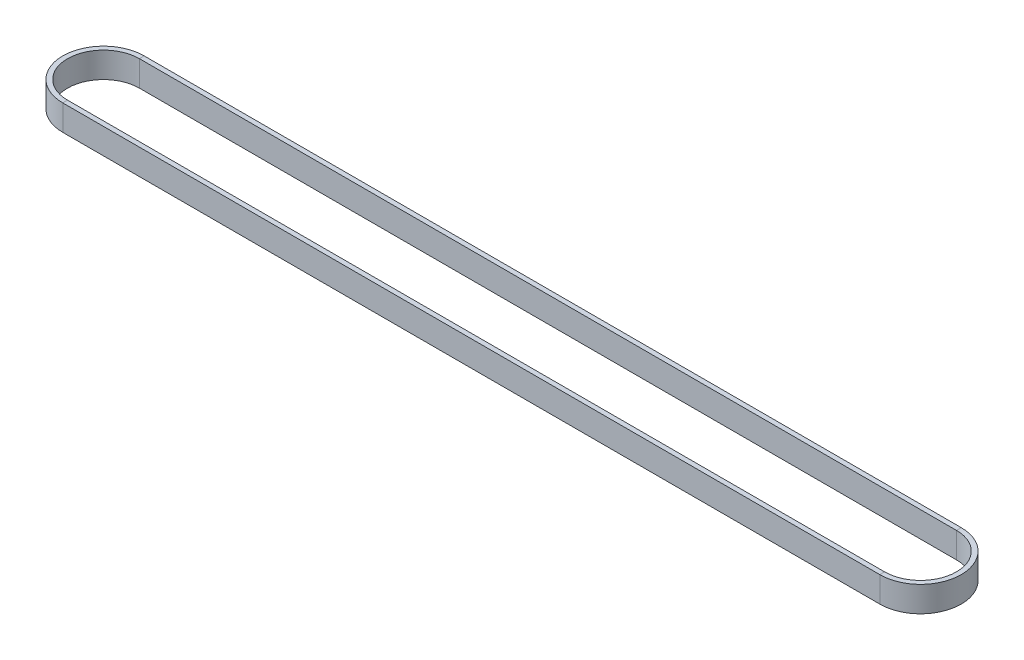
from build123d import *

# Parameters (mm, degrees)
SKETCH2_W = 1.905
SKETCH2_H = 10.16


with BuildPart() as part:
    # Sweep1: sweep along a path in Sketch1
    with BuildLine(Plane(origin=(0, 0, 0), x_dir=(1, 0, 0), z_dir=(0, 1, 0))) as sweep1_path:
        Line((0, 15.24), (325.005160504, 15.24))
        ThreePointArc((325.005160504, 15.24), (340.245160504, 0), (325.005160504, -15.24))
        Line((325.005160504, -15.24), (0, -15.24))
        ThreePointArc((0, -15.24), (-15.24, 0), (0, 15.24))
    # Sketch2 → Sweep1 (sweep)
    with BuildSketch(Plane(origin=(0, 0, 0), x_dir=(0, 0, -1), z_dir=(1, 0, 0))):
        with Locations((-15.24, 0)):
            Rectangle(SKETCH2_W, SKETCH2_H)
    sweep(path=sweep1_path.line)


solid = part.part
